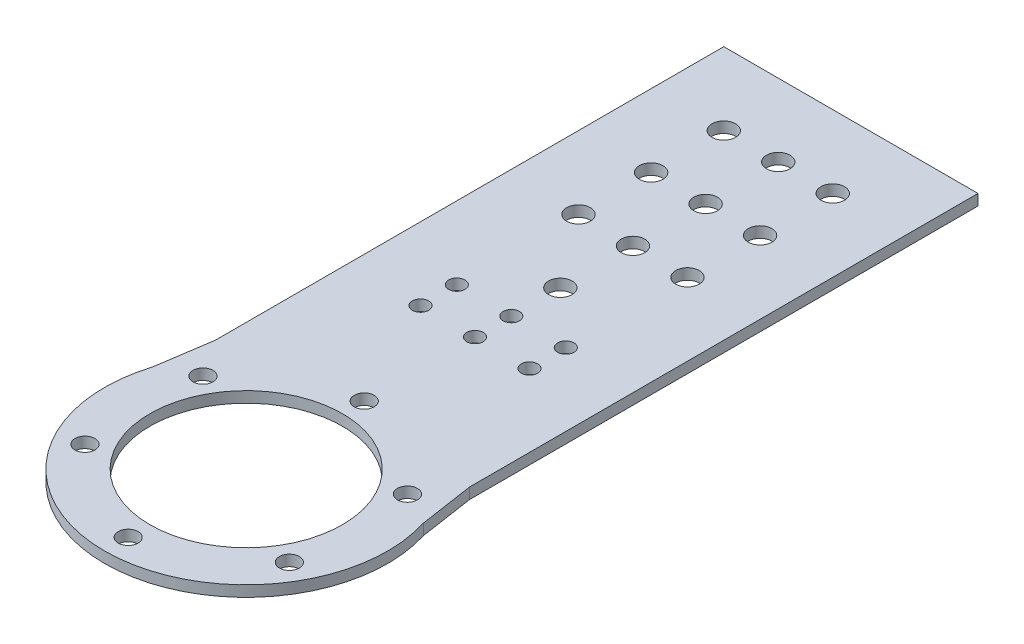
from build123d import *

# Parameters (mm, degrees)
SKETCH1_R            = 39
SKETCH1_R_2          = 26.5
BOSS_EXTRUDE1_DEPTH  = 1.5
SKETCH3_W            = 50
SKETCH3_H            = 51.5
BOSS_EXTRUDE2_DEPTH  = 1.5
BOSS_EXTRUDE4_DEPTH  = 1.5
SKETCH2_R            = 2.75
CUT_EXTRUDE1_DEPTH   = 2.5
CIRPATTERN1_COUNT    = 6
CUT_EXTRUDE2_START   = -4
SKETCH5_R            = 2.25
CUT_EXTRUDE2_DEPTH   = 5
LPATTERN1_COUNT      = 2
LPATTERN1_PITCH      = 15
LPATTERN1_COUNT_DIR2 = 2
LPATTERN1_PITCH_DIR2 = 10
LPATTERN2_COUNT      = 2
LPATTERN2_PITCH      = 15
LPATTERN2_COUNT_DIR2 = 2
LPATTERN2_PITCH_DIR2 = 10
CUT_EXTRUDE3_START   = -4
SKETCH7_R            = 3.25
CUT_EXTRUDE3_DEPTH   = 5
LPATTERN3_COUNT      = 3
LPATTERN3_PITCH      = 20
SKETCH8_R            = 3.25
CUT_EXTRUDE4_DEPTH   = 10
LPATTERN4_COUNT      = 4
LPATTERN4_PITCH      = 20


with BuildPart() as part:
    # Sketch1 → Boss-Extrude1 (new body, symmetric)
    with BuildSketch(Plane(origin=(0, 0, 0), x_dir=(1, 0, 0), z_dir=(0, 1, 0))):
        Circle(SKETCH1_R)
        Circle(SKETCH1_R_2, mode=Mode.SUBTRACT)
    extrude(amount=BOSS_EXTRUDE1_DEPTH, both=True)

    # Sketch3 → Boss-Extrude2 (add, symmetric)
    with BuildSketch(Plane(origin=(0, 0, 0), x_dir=(1, 0, 0), z_dir=(0, 1, 0))):
        with Locations((0, 52.25)):
            Rectangle(SKETCH3_W, SKETCH3_H)
    extrude(amount=BOSS_EXTRUDE2_DEPTH, both=True)

    # Sketch6 → Boss-Extrude4 (add, symmetric)
    with BuildSketch(Plane(origin=(0, 0, 0), x_dir=(1, 0, 0), z_dir=(0, 1, 0))):
        Polygon((-35, 166.5), (-35, 26.5), (-39, 0), (-14.981514186, 26.5), (16.520833333, 26.5), (39, 0), (35, 26.5), (35, 166.5), align=None)
    extrude(amount=BOSS_EXTRUDE4_DEPTH, both=True)

    # Sketch2 → Cut-Extrude1 (cut, symmetric)
    with BuildSketch(Plane(origin=(0, 0, 0), x_dir=(1, 0, 0), z_dir=(0, 1, 0))):
        with Locations((0, 32.5)):
            Circle(SKETCH2_R)
    cut_extrude1 = extrude(amount=CUT_EXTRUDE1_DEPTH, both=True, mode=Mode.SUBTRACT)

    # CirPattern1: Cut-Extrude1 ×6 about axis
    cirpattern1_axis = Axis((0, 0, 0), (0, 1, 0))
    for i in range(1, CIRPATTERN1_COUNT):
        add(cut_extrude1.rotate(cirpattern1_axis, i * 360 / CIRPATTERN1_COUNT), mode=Mode.SUBTRACT)

    # Sketch5 → Cut-Extrude2 (cut)
    with BuildSketch(Plane(origin=(0, 1.5, 0), x_dir=(1, 0, 0), z_dir=(0, 1, 0)).offset(CUT_EXTRUDE2_START)):
        with Locations((0, 73)):
            Circle(SKETCH5_R)
    cut_extrude2 = extrude(amount=CUT_EXTRUDE2_DEPTH, mode=Mode.SUBTRACT)

    # LPattern1: Cut-Extrude2 2 × 2
    with Locations(*[(i * LPATTERN1_PITCH, 0, j * LPATTERN1_PITCH_DIR2) for i in range(LPATTERN1_COUNT) for j in range(LPATTERN1_COUNT_DIR2) if (i, j) != (0, 0)]):
        add(cut_extrude2, mode=Mode.SUBTRACT)

    # LPattern2: Cut-Extrude2 2 × 2
    with Locations(*[(-i * LPATTERN2_PITCH, 0, j * LPATTERN2_PITCH_DIR2) for i in range(LPATTERN2_COUNT) for j in range(LPATTERN2_COUNT_DIR2) if (i, j) != (0, 0)]):
        add(cut_extrude2, mode=Mode.SUBTRACT)

    # Sketch7 → Cut-Extrude3 (cut)
    with BuildSketch(Plane(origin=(0, 1.5, 0), x_dir=(1, 0, 0), z_dir=(0, 1, 0)).offset(CUT_EXTRUDE3_START)):
        with Locations((-15, 146.5)):
            Circle(SKETCH7_R)
        with Locations((15, 146.5)):
            Circle(SKETCH7_R)
    cut_extrude3 = extrude(amount=CUT_EXTRUDE3_DEPTH, mode=Mode.SUBTRACT)

    # LPattern3: Cut-Extrude3 ×3
    with Locations(*[(0, 0, i * LPATTERN3_PITCH) for i in range(1, LPATTERN3_COUNT)]):
        add(cut_extrude3, mode=Mode.SUBTRACT)

    # Sketch8 → Cut-Extrude4 (cut)
    with BuildSketch(Plane(origin=(0, 1.5, 0), x_dir=(1, 0, 0), z_dir=(0, 1, 0))):
        with Locations((0, 146.5)):
            Circle(SKETCH8_R)
    cut_extrude4 = extrude(amount=-CUT_EXTRUDE4_DEPTH, mode=Mode.SUBTRACT)

    # LPattern4: Cut-Extrude4 ×4
    with Locations(*[(0, 0, i * LPATTERN4_PITCH) for i in range(1, LPATTERN4_COUNT)]):
        add(cut_extrude4, mode=Mode.SUBTRACT)


solid = part.part
